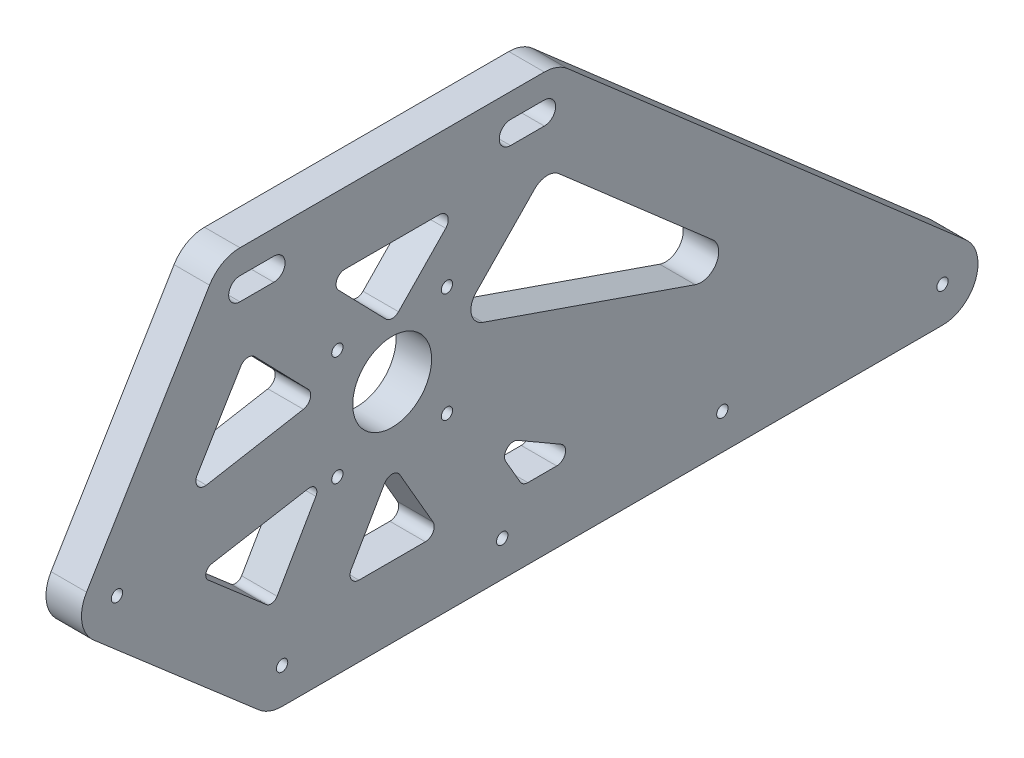
from build123d import *

# Parameters (mm, degrees)
SKETCH1_R           = 11.1125
SKETCH1_R_2         = 1.5875
SKETCH1_R_3         = 1.6
BOSS_EXTRUDE1_DEPTH = 10


with BuildPart() as part:
    # Sketch1 → Boss-Extrude1 (new body)
    with BuildSketch(Plane(origin=(0, 0, 0), x_dir=(0, 0, -1), z_dir=(1, 0, 0))):
        with BuildLine():
            Line((-31, -63.693575035), (155, -63.693575035))
            ThreePointArc((155, -63.693575035), (164.363641759, -57.203876021), (161.573840181, -46.158017638))
            Line((161.573840181, -46.158017638), (49.436340181, 51.668057396))
            ThreePointArc((49.436340181, 51.668057396), (46.372800987, 53.496141759), (42.8625, 54.1325))
            Line((42.8625, 54.1325), (-42.8625, 54.1325))
            ThreePointArc((-42.8625, 54.1325), (-47.78371281, 52.83776648), (-51.430593782, 49.288832897))
            Line((-51.430593782, 49.288832897), (-86.068093782, -8.267060862))
            ThreePointArc((-86.068093782, -8.267060862), (-87.375969658, -14.993496721), (-84.046536707, -20.982683219))
            Line((-84.046536707, -20.982683219), (-37.546536707, -61.252864495))
            ThreePointArc((-37.546536707, -61.252864495), (-34.49335837, -63.063550878), (-31, -63.693575035))
        make_face()
        Circle(SKETCH1_R, mode=Mode.SUBTRACT)
        with Locations((-15.4305, 15.4305)):
            Circle(SKETCH1_R_2, mode=Mode.SUBTRACT)
        with Locations((15.4305, 15.4305)):
            Circle(SKETCH1_R_2, mode=Mode.SUBTRACT)
        with Locations((15.4305, -15.4305)):
            Circle(SKETCH1_R_2, mode=Mode.SUBTRACT)
        with Locations((-15.4305, -15.4305)):
            Circle(SKETCH1_R_2, mode=Mode.SUBTRACT)
        with Locations((-77.5, -13.423393759)):
            Circle(SKETCH1_R_3, mode=Mode.SUBTRACT)
        with Locations((-31, -53.693575035)):
            Circle(SKETCH1_R_3, mode=Mode.SUBTRACT)
        with Locations((31, -53.693575035)):
            Circle(SKETCH1_R_3, mode=Mode.SUBTRACT)
        with Locations((93, -53.693575035)):
            Circle(SKETCH1_R_3, mode=Mode.SUBTRACT)
        with Locations((155, -53.693575035)):
            Circle(SKETCH1_R_3, mode=Mode.SUBTRACT)
        with BuildLine():
            Line((33.3375, 47.3075), (42.8625, 47.3075))
            ThreePointArc((42.8625, 47.3075), (46.0375, 44.1325), (42.8625, 40.9575))
            Line((42.8625, 40.9575), (33.3375, 40.9575))
            ThreePointArc((33.3375, 40.9575), (30.1625, 44.1325), (33.3375, 47.3075))
        make_face(mode=Mode.SUBTRACT)
        with BuildLine():
            Line((-33.3375, 47.3075), (-42.8625, 47.3075))
            ThreePointArc((-42.8625, 47.3075), (-46.0375, 44.1325), (-42.8625, 40.9575))
            Line((-42.8625, 40.9575), (-33.3375, 40.9575))
            ThreePointArc((-33.3375, 40.9575), (-30.1625, 44.1325), (-33.3375, 47.3075))
        make_face(mode=Mode.SUBTRACT)
        with BuildLine():
            Line((13.297041151, 34.1325), (-13.297041151, 34.1325))
            ThreePointArc((-13.297041151, 34.1325), (-15.599695746, 32.606040867), (-15.090423831, 29.890725455))
            Line((-15.090423831, 29.890725455), (-1.793382679, 16.1996979))
            ThreePointArc((-1.793382679, 16.1996979), (0, 15.441472444), (1.793382679, 16.1996979))
            Line((1.793382679, 16.1996979), (15.090423831, 29.890725455))
            ThreePointArc((15.090423831, 29.890725455), (15.599695746, 32.606040867), (13.297041151, 34.1325))
        make_face(mode=Mode.SUBTRACT)
        with BuildLine():
            Line((-51.815124471, -22.438391905), (-35.436810722, -36.622427682))
            ThreePointArc((-35.436810722, -36.622427682), (-33.795573215, -37.08283305), (-32.395452573, -36.11056979))
            Line((-32.395452573, -36.11056979), (-21.47657674, -17.198522087))
            ThreePointArc((-21.47657674, -17.198522087), (-21.568587763, -15.053852045), (-23.549955622, -14.22786353))
            Line((-23.549955622, -14.22786353), (-50.847145204, -18.955875456))
            ThreePointArc((-50.847145204, -18.955875456), (-52.43276537, -20.390931102), (-51.815124471, -22.438391905))
        make_face(mode=Mode.SUBTRACT)
        with BuildLine():
            Line((-42.663433079, 25.069654772), (-54.916393111, 4.709349732))
            ThreePointArc((-54.916393111, 4.709349732), (-54.834634818, 2.004177703), (-52.338364397, 0.958580214))
            Line((-52.338364397, 0.958580214), (-25.011725561, 5.798578931))
            ThreePointArc((-25.011725561, 5.798578931), (-23.068694594, 7.492029199), (-23.65434815, 10.002039769))
            Line((-23.65434815, 10.002039769), (-38.728026954, 25.522346093))
            ThreePointArc((-38.728026954, 25.522346093), (-40.807101694, 26.264193912), (-42.663433079, 25.069654772))
        make_face(mode=Mode.SUBTRACT)
        with BuildLine():
            Line((-11.514428415, -39.943575035), (-2.165063509, -23.75))
            ThreePointArc((-2.165063509, -23.75), (0, -22.5), (2.165063509, -23.75))
            Line((2.165063509, -23.75), (11.514428415, -39.943575035))
            ThreePointArc((11.514428415, -39.943575035), (11.514428415, -42.443575035), (9.349364905, -43.693575035))
            Line((9.349364905, -43.693575035), (-9.349364905, -43.693575035))
            ThreePointArc((-9.349364905, -43.693575035), (-11.514428415, -42.443575035), (-11.514428415, -39.943575035))
        make_face(mode=Mode.SUBTRACT)
        with BuildLine():
            Line((38.216878365, -43.693575035), (46.349364905, -43.693575035))
            ThreePointArc((46.349364905, -43.693575035), (48.764179471, -41.840622647), (47.599364905, -39.028511525))
            Line((47.599364905, -39.028511525), (35.400635095, -31.985571585))
            ThreePointArc((35.400635095, -31.985571585), (32.382868142, -32.382868142), (31.985571585, -35.400635095))
            Line((31.985571585, -35.400635095), (36.051814855, -42.443575035))
            ThreePointArc((36.051814855, -42.443575035), (36.966878365, -43.358638544), (38.216878365, -43.693575035))
        make_face(mode=Mode.SUBTRACT)
        with BuildLine():
            Line((47.00332879, 27.249721463), (90.259443654, -10.48587937))
            ThreePointArc((90.259443654, -10.48587937), (91.29812152, -16.761486275), (85.335889386, -18.978213981))
            Line((85.335889386, -18.978213981), (25.545919003, 1.733639317))
            ThreePointArc((25.545919003, 1.733639317), (22.317964542, 5.302436868), (23.59578782, 9.941744319))
            Line((23.59578782, 9.941744319), (40.12964334, 26.965491854))
            ThreePointArc((40.12964334, 26.965491854), (43.509833256, 28.4776736), (47.00332879, 27.249721463))
        make_face(mode=Mode.SUBTRACT)
    extrude(amount=BOSS_EXTRUDE1_DEPTH)


solid = part.part
